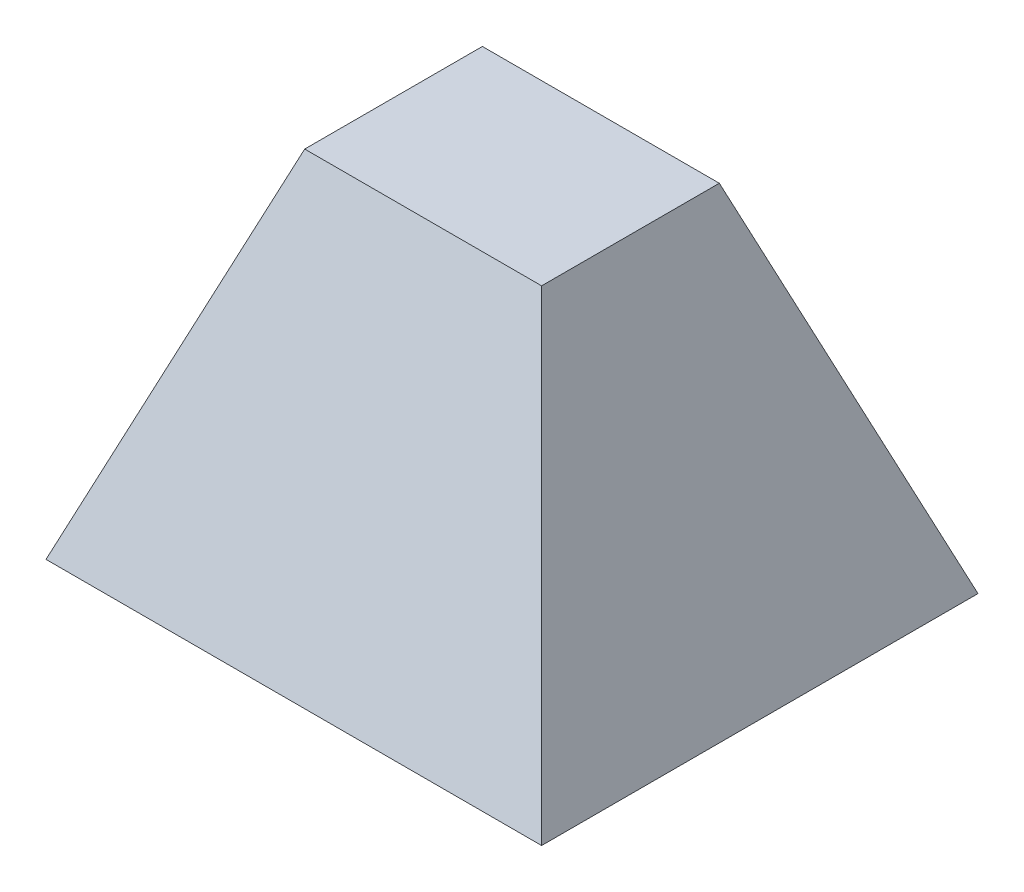
from build123d import *

# Parameters (mm, degrees)
SKETCH5_W           = 20
SKETCH5_H           = 15
BOSS_EXTRUDE1_DEPTH = 30
BOSS_EXTRUDE1_TAPER = -20


with BuildPart() as part:
    # Sketch5 → Boss-Extrude1 (new body)
    with BuildSketch(Plane(origin=(0, 0, 0), x_dir=(1, 0, 0), z_dir=(0, 1, 0))):
        with Locations((205, -75)):
            Rectangle(SKETCH5_W, SKETCH5_H)
    extrude(amount=-BOSS_EXTRUDE1_DEPTH, taper=BOSS_EXTRUDE1_TAPER)


solid = part.part
